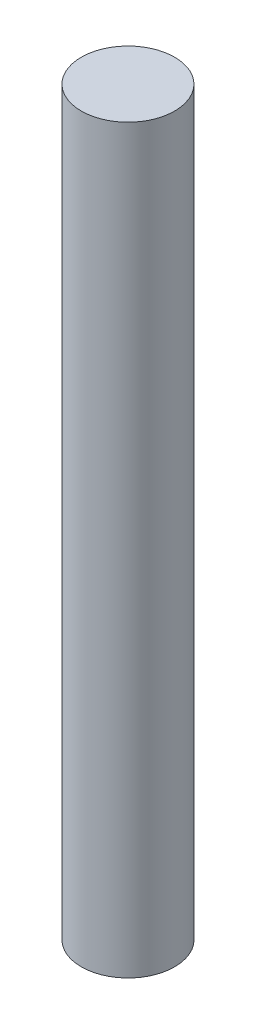
from build123d import *

# Parameters (mm, degrees)
SKETCH1_R           = 4
BOSS_EXTRUDE1_DEPTH = 63.5


with BuildPart() as part:
    # Sketch1 → Boss-Extrude1 (new body)
    with BuildSketch(Plane(origin=(0, 0, 0), x_dir=(1, 0, 0), z_dir=(0, 1, 0))):
        Circle(SKETCH1_R)
    extrude(amount=BOSS_EXTRUDE1_DEPTH)


solid = part.part
